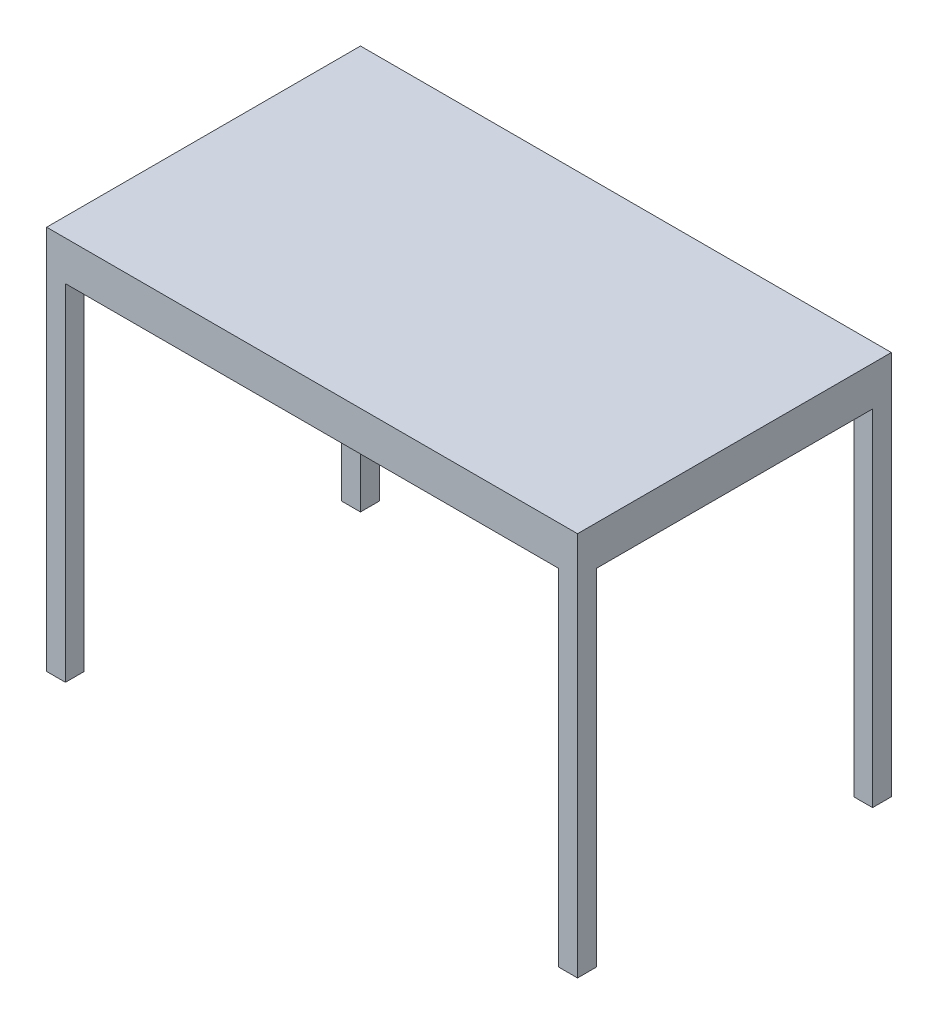
from build123d import *

# Parameters (mm, degrees)
CROQUIS1_W                = 38.1
CROQUIS1_H                = 38.1
SALIENTE_EXTRUIR1_DEPTH   = 700
SALIENTE_EXTRUIR1_2_DEPTH = 700
SALIENTE_EXTRUIR1_3_DEPTH = 700
SALIENTE_EXTRUIR1_4_DEPTH = 700
CROQUIS2_W                = 1076.2
CROQUIS2_H                = 636.2
SALIENTE_EXTRUIR2_DEPTH   = 80


with BuildPart() as part:
    # Croquis1 → Saliente-Extruir1 (new body)
    with BuildSketch(Plane(origin=(0, 0, 0), x_dir=(1, 0, 0), z_dir=(0, 1, 0))):
        with Locations((19.05, -19.05)):
            Rectangle(CROQUIS1_W, CROQUIS1_H)
    extrude(amount=SALIENTE_EXTRUIR1_DEPTH)



with BuildPart() as body_2:
    # Croquis1 → Saliente-Extruir1 2 (new body)
    with BuildSketch(Plane(origin=(0, 0, 0), x_dir=(1, 0, 0), z_dir=(0, 1, 0))):
        with Locations((1057.15, -19.05)):
            Rectangle(CROQUIS1_W, CROQUIS1_H)
    extrude(amount=SALIENTE_EXTRUIR1_2_DEPTH)


with BuildPart() as body_3:
    # Croquis1 → Saliente-Extruir1 3 (new body)
    with BuildSketch(Plane(origin=(0, 0, 0), x_dir=(1, 0, 0), z_dir=(0, 1, 0))):
        with Locations((1057.15, -617.15)):
            Rectangle(CROQUIS1_W, CROQUIS1_H)
    extrude(amount=SALIENTE_EXTRUIR1_3_DEPTH)


with BuildPart() as body_4:
    # Croquis1 → Saliente-Extruir1 4 (new body)
    with BuildSketch(Plane(origin=(0, 0, 0), x_dir=(1, 0, 0), z_dir=(0, 1, 0))):
        with Locations((19.05, -617.15)):
            Rectangle(CROQUIS1_W, CROQUIS1_H)
    extrude(amount=SALIENTE_EXTRUIR1_4_DEPTH)


with BuildPart() as part_1:
    add(part.part)

    add(body_2.part)  # Saliente-Extruir2 merges body 2

    add(body_3.part)  # Saliente-Extruir2 merges body 3

    add(body_4.part)  # Saliente-Extruir2 merges body 4
    # Croquis2 → Saliente-Extruir2 (add)
    with BuildSketch(Plane(origin=(0, 700, 0), x_dir=(1, 0, 0), z_dir=(0, 1, 0))):
        with Locations((538.1, -318.1)):
            Rectangle(CROQUIS2_W, CROQUIS2_H)
    extrude(amount=SALIENTE_EXTRUIR2_DEPTH)


solid = part_1.part
